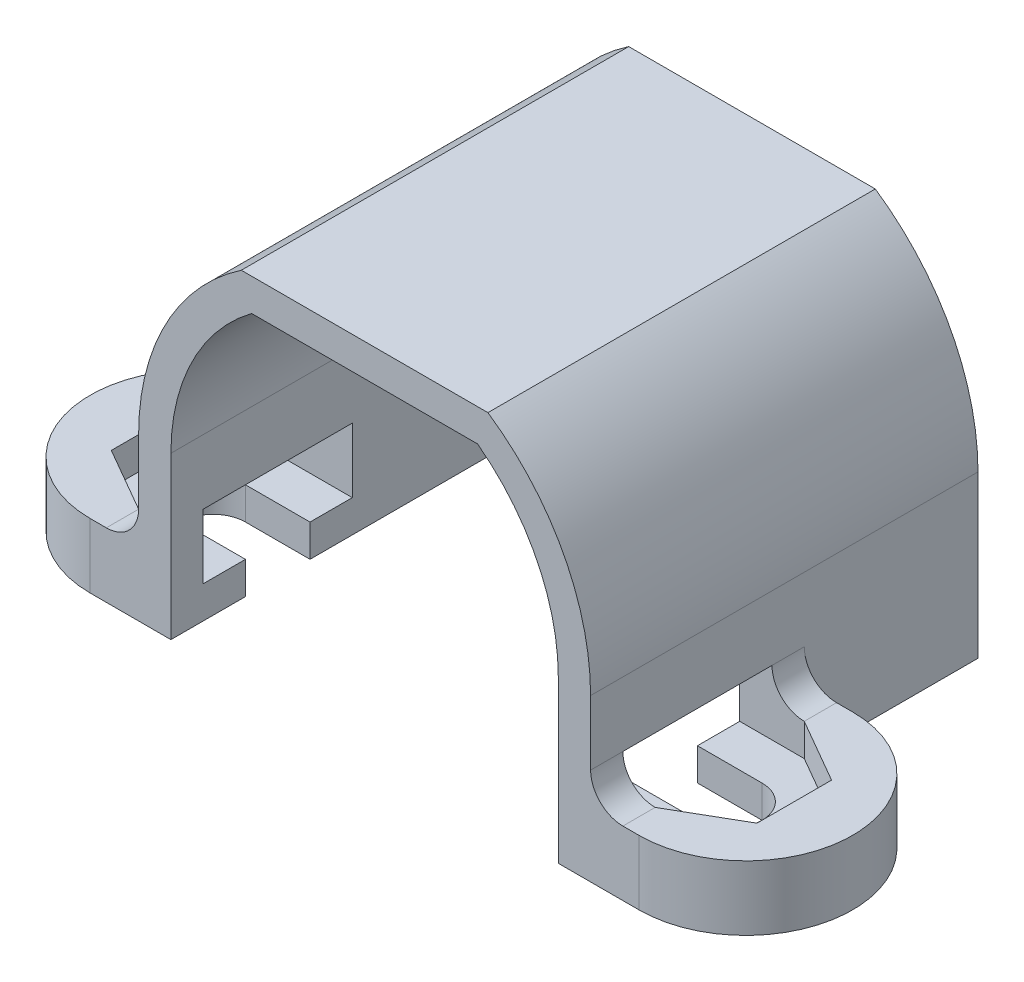
from build123d import *

# Parameters (mm, degrees)
BOSS_EXTRUDE1_DEPTH     = 12
BOSS_EXTRUDE3_DEPTH     = 2
FILLET2_R               = 1
CUT_EXTRUDE7_DEPTH      = 3
CUT_EXTRUDE8_DEPTH      = 1
CUT_EXTRUDE8_DEPTH_BACK = 1


with BuildPart() as part:
    # Sketch1 → Boss-Extrude1 (new body)
    with BuildSketch(Plane.XY):
        with BuildLine():
            Line((3.5, 10), (-3.5, 10))
            ThreePointArc((-3.5, 10), (-5.340169944, 7.795084972), (-6, 5))
            Line((-6, 5), (-6, 0))
            Line((-6, 0), (-7, 0))
            Line((-7, 0), (-7, 1))
            Line((-7, 1), (-7, 5))
            ThreePointArc((-7, 5), (-6.155773268, 8.395374624), (-3.819705149, 11))
            Line((-3.819705149, 11), (3.819705149, 11))
            ThreePointArc((3.819705149, 11), (6.155773268, 8.395374624), (7, 5))
            Line((7, 5), (7, 1))
            Line((7, 1), (7, 0))
            Line((7, 0), (6, 0))
            Line((6, 0), (6, 5))
            ThreePointArc((6, 5), (5.340169944, 7.795084972), (3.5, 10))
        make_face()
    extrude(amount=-BOSS_EXTRUDE1_DEPTH)

    # Sketch4 → Boss-Extrude3 (add)
    with BuildSketch(Plane.XZ):
        with BuildLine():
            Line((-7, 0), (-8.5, 0))
            ThreePointArc((-8.5, 0), (-11.809401077, -3.309401077), (-8.5, -6.618802154))
            Line((-8.5, -6.618802154), (-7, -6.618802154))
            Line((-7, -6.618802154), (-7, 0))
        make_face()
        with BuildLine():
            ThreePointArc((8.5, -6.618802154), (11.809401077, -3.309401077), (8.5, 0))
            Line((8.5, 0), (7, 0))
            Line((7, 0), (7, -6.618802154))
            Line((7, -6.618802154), (8.5, -6.618802154))
        make_face()
    extrude(amount=-BOSS_EXTRUDE3_DEPTH)

    # Fillet2
    fillet2_edges = [part.edges().sort_by_distance(p)[0] for p in [
        (-7, 2, -3.309401077),
        (7, 2, -3.309401077),
    ]]
    fillet(fillet2_edges, radius=FILLET2_R)

    # Sketch5 → Cut-Extrude7 (cut)
    with BuildSketch(Plane(origin=(0, 2, 0), x_dir=(1, 0, 0), z_dir=(0, 1, 0))):
        with BuildLine():
            Line((-7, 4.309401077), (-8, 4.309401077))
            ThreePointArc((-8, 4.309401077), (-9, 3.309401077), (-8, 2.309401077))
            Line((-8, 2.309401077), (-7, 2.309401077))
            Line((-7, 2.309401077), (-3.819705149, 2.309401077))
            Line((-3.819705149, 2.309401077), (-3.819705149, 4.309401077))
            Line((-3.819705149, 4.309401077), (-7, 4.309401077))
        make_face()
        with BuildLine():
            Line((3.819705149, 2.309401077), (7, 2.309401077))
            Line((7, 2.309401077), (8, 2.309401077))
            ThreePointArc((8, 2.309401077), (9, 3.309401077), (8, 4.309401077))
            Line((8, 4.309401077), (7, 4.309401077))
            Line((7, 4.309401077), (3.819705149, 4.309401077))
            Line((3.819705149, 4.309401077), (3.819705149, 2.309401077))
        make_face()
    extrude(amount=-CUT_EXTRUDE7_DEPTH, mode=Mode.SUBTRACT)

    # Sketch6 → Cut-Extrude8 (cut, two sides)
    with BuildSketch(Plane(origin=(0, 2, 0), x_dir=(1, 0, 0), z_dir=(0, 1, 0))) as cut_extrude8_sk:
        Polygon((-8, 5.618802154), (-10, 4.464101615), (-10, 2.154700538), (-8, 1), (-6, 1), (-6, 5.618802154), align=None)
        Polygon((6, 1), (8, 1), (10, 2.154700538), (10, 4.464101615), (8, 5.618802154), (6, 5.618802154), align=None)
    extrude(amount=CUT_EXTRUDE8_DEPTH, mode=Mode.SUBTRACT)
    extrude(cut_extrude8_sk.sketch, amount=-CUT_EXTRUDE8_DEPTH_BACK, mode=Mode.SUBTRACT)


solid = part.part
